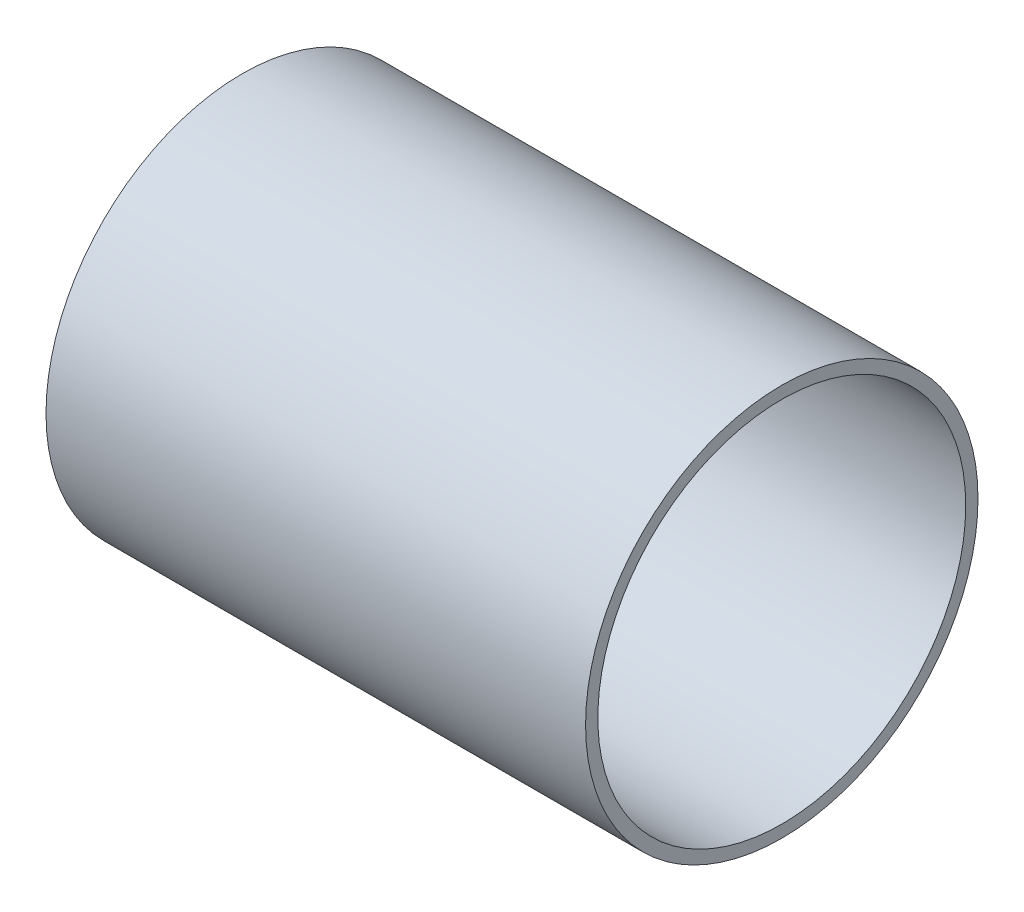
from build123d import *

# Parameters (mm, degrees)
SKETCH1_R           = 50.8
SKETCH1_R_2         = 47.625
BOSS_EXTRUDE1_DEPTH = 139.7


with BuildPart() as part:
    # Sketch1 → Boss-Extrude1 (new body)
    with BuildSketch(Plane(origin=(0, 0, 0), x_dir=(0, 0, -1), z_dir=(1, 0, 0))):
        Circle(SKETCH1_R)
        Circle(SKETCH1_R_2, mode=Mode.SUBTRACT)
    extrude(amount=BOSS_EXTRUDE1_DEPTH)


solid = part.part
